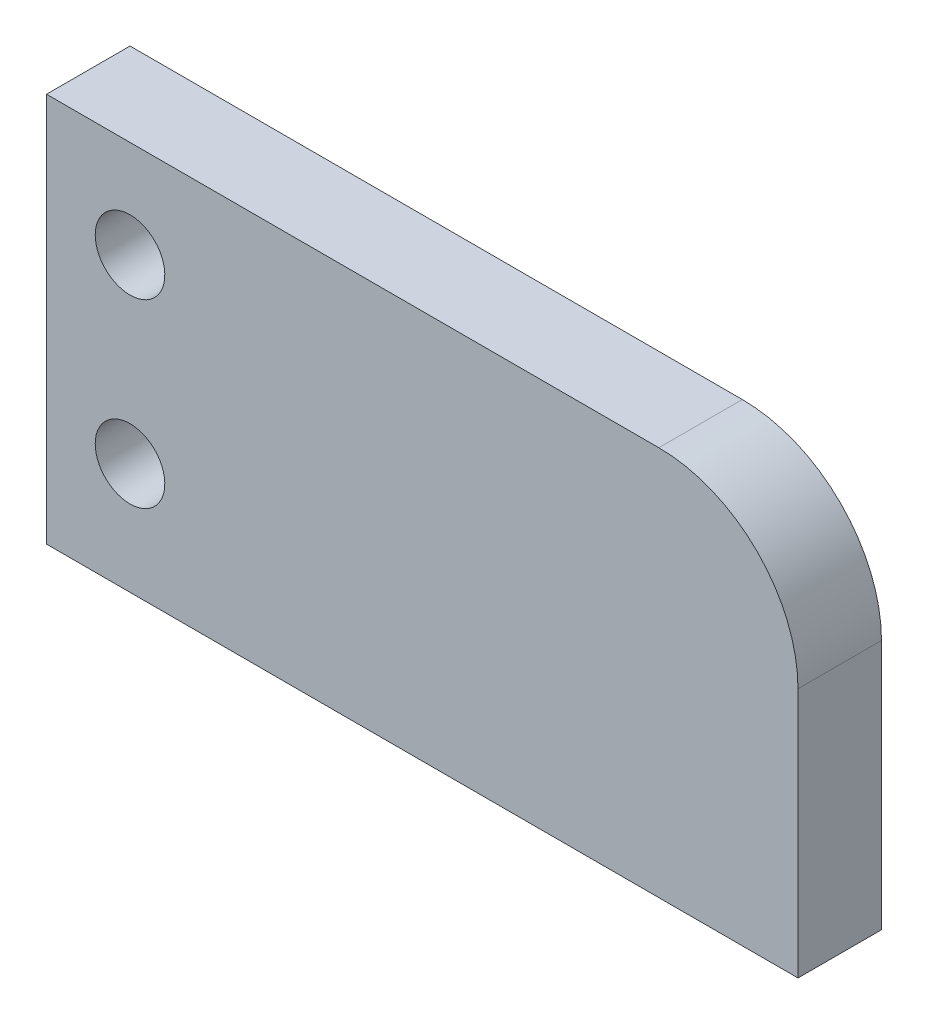
from build123d import *

# Parameters (mm, degrees)
SKETCH1_W           = 19
SKETCH1_H           = 58
BOSS_EXTRUDE1_DEPTH = 54
SKETCH2_3_R         = 20
SKETCH2_3_R_2       = 15.5
BOSS_EXTRUDE2_DEPTH = 50
SKETCH2_R           = 1.9
CUT_EXTRUDE1_DEPTH  = 10
FILLET1_R           = 10
BOSS_EXTRUDE3_DEPTH = 50
SKETCH4_R           = 1.25
CUT_EXTRUDE2_DEPTH  = 100.523866484
SKETCH5_W           = 17
SKETCH5_H           = 14
CUT_EXTRUDE3_DEPTH  = 2
SKETCH7_W           = 50
SKETCH7_H           = 57
CUT_EXTRUDE4_DEPTH  = 94.701654201
SKETCH8_W           = 3
SKETCH8_H           = 14
BOSS_EXTRUDE4_DEPTH = 10
FILLET2_R           = 5


with BuildPart() as part:
    # Sketch1 → Boss-Extrude1 (new body)
    with BuildSketch(Plane.XY):
        with Locations((9.5, 29)):
            Rectangle(SKETCH1_W, SKETCH1_H)
    extrude(amount=BOSS_EXTRUDE1_DEPTH)

    # Sketch2_3 → Boss-Extrude2 (add)
    with BuildSketch(Plane.ZY):
        with Locations((27.5, 29)):
            Circle(SKETCH2_3_R)
        with Locations((27.5, 29)):
            Circle(SKETCH2_3_R_2, mode=Mode.SUBTRACT)
    extrude(amount=-BOSS_EXTRUDE2_DEPTH)

    # Sketch2 → Cut-Extrude1 (cut)
    with BuildSketch(Plane.ZY):
        with Locations((9.25, 29)):
            Circle(SKETCH2_R)
        with Locations((45.75, 29)):
            Circle(SKETCH2_R)
    extrude(amount=-CUT_EXTRUDE1_DEPTH, mode=Mode.SUBTRACT)

    # Fillet1
    fillet1_edges = [part.edges().sort_by_distance(p)[0] for p in [
        (9.5, 0, 0),
    ]]
    fillet(fillet1_edges, radius=FILLET1_R)

    # Sketch3 → Boss-Extrude3 (add)
    with BuildSketch(Plane(origin=(0, 0, 0), x_dir=(0, 0, -1), z_dir=(1, 0, 0))):
        Polygon((0, 0), (0, 57), (0, 67), (-5, 67), (-5, 0), align=None)
    extrude(amount=-BOSS_EXTRUDE3_DEPTH)

    # Sketch4 → Cut-Extrude2 (cut, through all)
    with BuildSketch(Plane(origin=(0, 0, 0), x_dir=(-1, 0, 0), z_dir=(0, 0, -1))):
        with Locations((14, 57)):
            Circle(SKETCH4_R)
        Polygon((0, 0), (50, 0), (50, 67), (17, 67), (17, 53), (0, 53), align=None)
        with Locations((14, 63.5)):
            Circle(SKETCH4_R)
    extrude(amount=-CUT_EXTRUDE2_DEPTH, mode=Mode.SUBTRACT)

    # Sketch5 → Cut-Extrude3 (cut)
    with BuildSketch(Plane(origin=(0, 0, 0), x_dir=(-1, 0, 0), z_dir=(0, 0, -1))):
        with Locations((8.5, 60)):
            Rectangle(SKETCH5_W, SKETCH5_H)
    extrude(amount=-CUT_EXTRUDE3_DEPTH, mode=Mode.SUBTRACT)

    # Sketch7 → Cut-Extrude4 (cut, through all)
    with BuildSketch(Plane(origin=(0, 58, 0), x_dir=(1, 0, 0), z_dir=(0, 1, 0))):
        with Locations((25, -28.5)):
            Rectangle(SKETCH7_W, SKETCH7_H)
    extrude(amount=-CUT_EXTRUDE4_DEPTH, mode=Mode.SUBTRACT)

    # Sketch8 → Boss-Extrude4 (add)
    with BuildSketch(Plane(origin=(0, 0, 0), x_dir=(0, 0, -1), z_dir=(1, 0, 0))):
        with Locations((-3.5, 60)):
            Rectangle(SKETCH8_W, SKETCH8_H)
    extrude(amount=BOSS_EXTRUDE4_DEPTH)

    # Fillet2
    fillet2_edges = [part.edges().sort_by_distance(p)[0] for p in [
        (10, 67, 3.5),
    ]]
    fillet(fillet2_edges, radius=FILLET2_R)


solid = part.part
